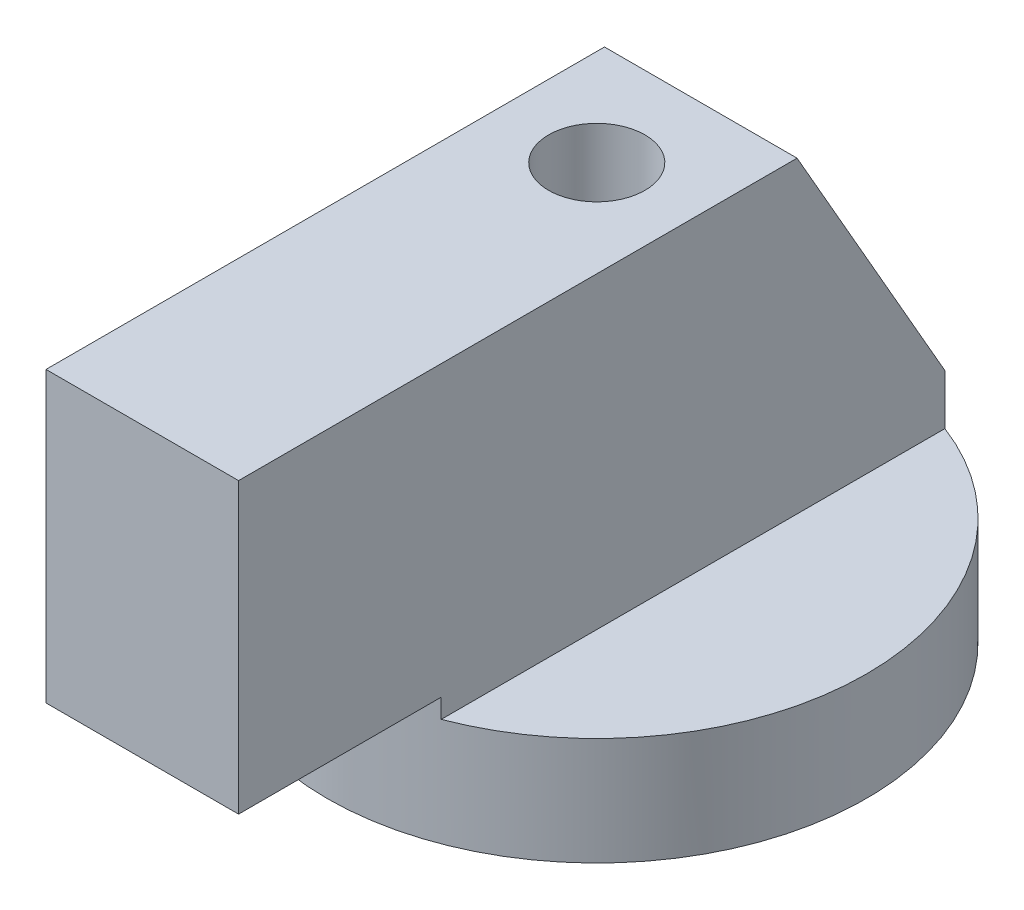
from build123d import *

# Parameters (mm, degrees)
IZIM1_R                     = 14
Y_KSEKLIK_EKSTR_ZYON1_DEPTH = 5.6
Y_KSEKLIK_EKSTR_ZYON2_DEPTH = 5
IZIM3_OUTSIDE_W             = 40.324
IZIM3_OUTSIDE_H             = 49.924
IZIM3_OUTSIDE_R             = 14
KES_EKSTR_ZYON1_DEPTH       = 6.6
KES_EKSTR_ZYON2_DEPTH       = 10
IZIM5_R                     = 2.5
KES_EKSTR_ZYON3_DEPTH       = 22.6
IZIM6_W                     = 3.5
IZIM6_H                     = 8
Y_KSEKLIK_EKSTR_ZYON3_DEPTH = 0.1


with BuildPart() as part:
    # Çizim1 → Yükseklik-Ekstrüzyon1 (new body)
    with BuildSketch(Plane(origin=(0, 0, 0), x_dir=(1, 0, 0), z_dir=(0, 1, 0))):
        Circle(IZIM1_R)
    extrude(amount=-Y_KSEKLIK_EKSTR_ZYON1_DEPTH)

    # Çizim2 → Yükseklik-Ekstrüzyon2 (add, symmetric)
    with BuildSketch(Plane(origin=(0, 0, 0), x_dir=(0, 0, -1), z_dir=(1, 0, 0))):
        Polygon((-14, 0), (-14, 1), (-23.6, 1), (-23.6, 16), (5.4, 16), (14, 1), (14, 0), align=None)
    extrude(amount=Y_KSEKLIK_EKSTR_ZYON2_DEPTH, both=True)

    # Çizim3 outside → Kes-Ekstrüzyon1 (cut)
    with BuildSketch(Plane.XZ.offset(5.6)):
        with Locations((0, 4.8)):
            Rectangle(IZIM3_OUTSIDE_W, IZIM3_OUTSIDE_H)
        Circle(IZIM3_OUTSIDE_R, mode=Mode.SUBTRACT)
    extrude(amount=-KES_EKSTR_ZYON1_DEPTH, mode=Mode.SUBTRACT)

    # Çizim4 → Kes-Ekstrüzyon2 (cut)
    with BuildSketch(Plane.XZ.offset(5.6)):
        with BuildLine():
            ThreePointArc((5, -13.076697), (2.542267, -13.767239), (0, -14))
            Line((0, -14), (5, -14))
            Line((5, -14), (5, -13.076697))
        make_face()
        with BuildLine():
            Line((-5, -13.076697), (-5, -14))
            Line((-5, -14), (0, -14))
            ThreePointArc((0, -14), (-2.542267, -13.767239), (-5, -13.076697))
        make_face()
    extrude(amount=-KES_EKSTR_ZYON2_DEPTH, mode=Mode.SUBTRACT)

    # Çizim5 → Kes-Ekstrüzyon3 (cut, through all)
    with BuildSketch(Plane.XZ.offset(5.6)):
        Circle(IZIM5_R)
    extrude(amount=-KES_EKSTR_ZYON3_DEPTH, mode=Mode.SUBTRACT)

    # Çizim6 → Yükseklik-Ekstrüzyon3 (add)
    with BuildSketch(Plane(origin=(0, 6.288333, -10.968022), x_dir=(-1, 0, 0), z_dir=(0, 0.497384, -0.86753))):
        with Locations((0, 1.932636)):
            Rectangle(IZIM6_W, IZIM6_H)
    extrude(amount=Y_KSEKLIK_EKSTR_ZYON3_DEPTH)


solid = part.part
